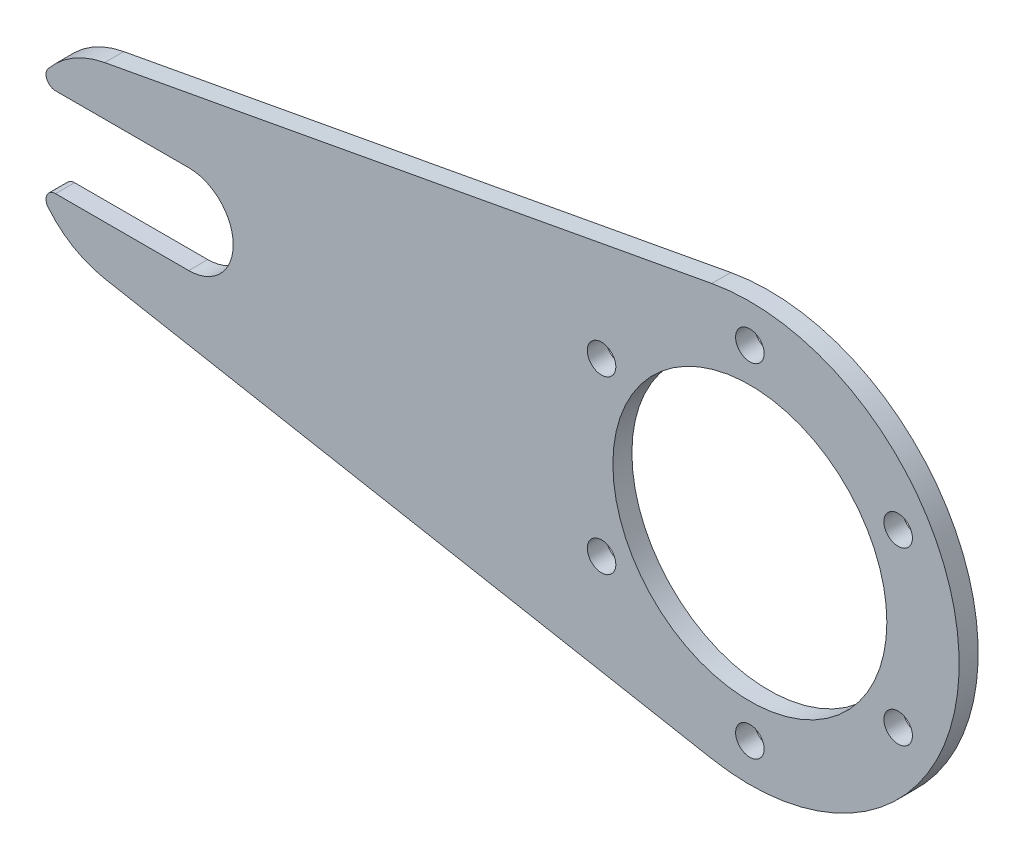
from build123d import *

# Parameters (mm, degrees)
SKETCH1_R           = 4.7625
SKETCH1_R_2         = 45.72
BOSS_EXTRUDE1_DEPTH = 6.35


with BuildPart() as part:
    # Sketch1 → Boss-Extrude1 (new body)
    with BuildSketch(Plane.XY):
        with BuildLine():
            Line((-215.322727273, 31.220796272), (-12.7, 68.685751798))
            ThreePointArc((-12.7, 68.685751798), (69.85, 0), (-12.7, -68.685751798))
            Line((-12.7, -68.685751798), (-215.322727273, -31.220796272))
            ThreePointArc((-215.322727273, -31.220796272), (-225.746283623, -27.308293553), (-234.178235051, -20.037777778))
            ThreePointArc((-234.178235051, -20.037777778), (-234.582694183, -16.670432885), (-231.715411546, -14.859))
            Line((-231.715411546, -14.859), (-187.265411546, -14.859))
            ThreePointArc((-187.265411546, -14.859), (-172.406411546, 0), (-187.265411546, 14.859))
            Line((-187.265411546, 14.859), (-231.715411546, 14.859))
            ThreePointArc((-231.715411546, 14.859), (-234.582694183, 16.670432885), (-234.178235051, 20.037777778))
            ThreePointArc((-234.178235051, 20.037777778), (-225.746283623, 27.308293553), (-215.322727273, 31.220796272))
        make_face()
        with Locations((0, 57.15)):
            Circle(SKETCH1_R, mode=Mode.SUBTRACT)
        with Locations((49.493351826, 28.575)):
            Circle(SKETCH1_R, mode=Mode.SUBTRACT)
        with Locations((49.493351826, -28.575)):
            Circle(SKETCH1_R, mode=Mode.SUBTRACT)
        with Locations((0, -57.15)):
            Circle(SKETCH1_R, mode=Mode.SUBTRACT)
        with Locations((-49.493351826, -28.575)):
            Circle(SKETCH1_R, mode=Mode.SUBTRACT)
        with Locations((-49.493351826, 28.575)):
            Circle(SKETCH1_R, mode=Mode.SUBTRACT)
        Circle(SKETCH1_R_2, mode=Mode.SUBTRACT)
    extrude(amount=BOSS_EXTRUDE1_DEPTH)


solid = part.part
